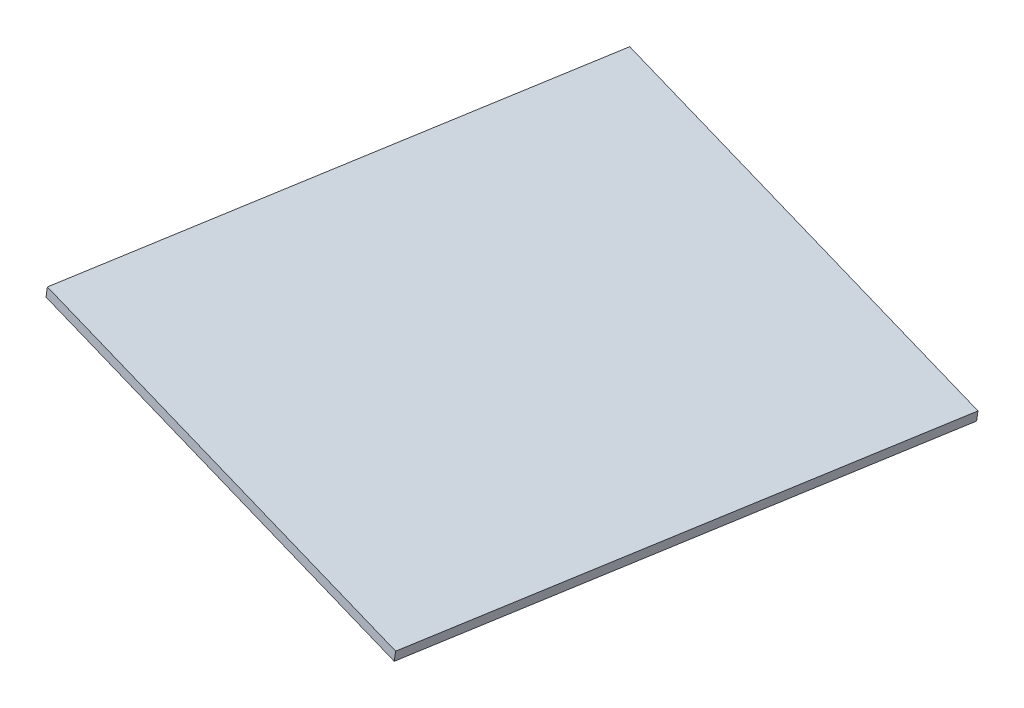
from build123d import *

# Parameters (mm, degrees)
BOSS_EXTRUDE1_DEPTH = 3


with BuildPart() as part:
    # Sketch1 → Boss-Extrude1 (new body)
    with BuildSketch(Plane(origin=(492.531820934, 3075.376385941, 146.83207961), x_dir=(0.940925169, -0.167327537, 0.29438295), z_dir=(-0.167151694, -0.985589642, -0.02594937))):
        Polygon((21.508048483, 701.207152327), (150.275926486, 683.351240294), (129.175443108, 531.185141775), (0.407565104, 549.041053807), align=None)
    extrude(amount=-BOSS_EXTRUDE1_DEPTH)


solid = part.part
